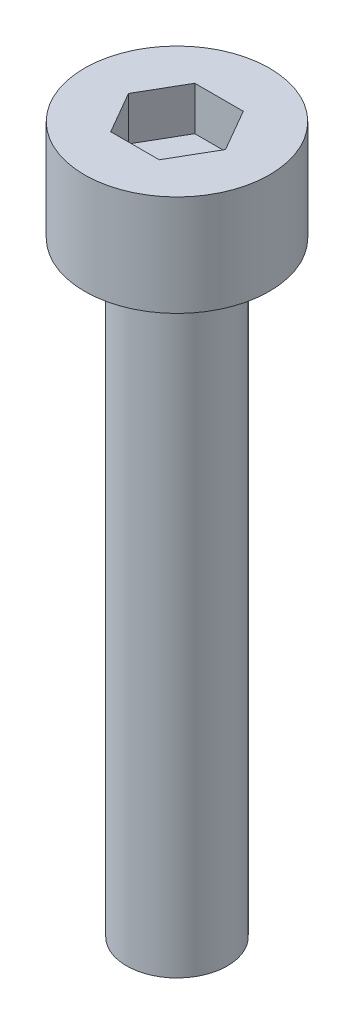
from build123d import *

# Parameters (mm, degrees)
SKETCH_1_R            = 2.75
EXTRUDE_248_DEPTH     = 3
CUT_EXTRUDE_378_DEPTH = 1.3
SKETCH_3_R            = 1.5
EXTRUDE_479_DEPTH     = 18


with BuildPart() as part:
    # 草图1 → Extrude 248 (new body)
    with BuildSketch(Plane(origin=(0, 0, 0), x_dir=(1, 0, 0), z_dir=(0, 1, 0))):
        Circle(SKETCH_1_R)
    extrude(amount=EXTRUDE_248_DEPTH)

    # 草图2 → Cut-Extrude 378 (cut)
    with BuildSketch(Plane(origin=(0, 3, 0), x_dir=(1, 0, 0), z_dir=(0, 1, 0))):
        Polygon((1.443375673, 0), (0.721687836, 1.25), (-0.721687836, 1.25), (-1.443375673, 0), (-0.721687836, -1.25), (0.721687836, -1.25), align=None)
    extrude(amount=-CUT_EXTRUDE_378_DEPTH, mode=Mode.SUBTRACT)

    # 草图3 → Extrude 479 (add)
    with BuildSketch(Plane.XZ):
        Circle(SKETCH_3_R)
    extrude(amount=EXTRUDE_479_DEPTH)


solid = part.part
